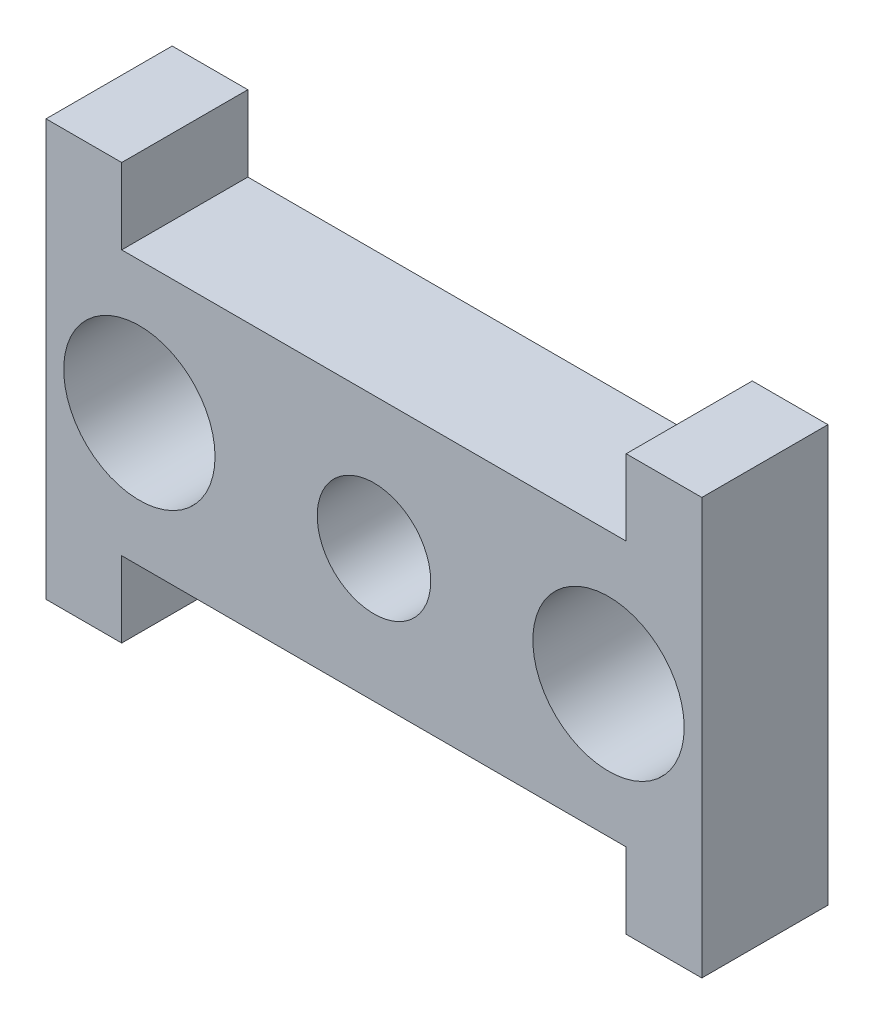
from build123d import *

# Parameters (mm, degrees)
SKETCH1_R           = 3
SKETCH1_R_2         = 2.25
BOSS_EXTRUDE1_DEPTH = 5


with BuildPart() as part:
    # Sketch1 → Boss-Extrude1 (new body)
    with BuildSketch(Plane.XY):
        Polygon((-13, 8.25), (-13, -8.25), (-10, -8.25), (-10, -5.25), (10, -5.25), (10, -8.25), (13, -8.25), (13, 8.25), (10, 8.25), (10, 5.25), (-10, 5.25), (-10, 8.25), align=None)
        with Locations((-9.3, 0)):
            Circle(SKETCH1_R, mode=Mode.SUBTRACT)
        Circle(SKETCH1_R_2, mode=Mode.SUBTRACT)
        with Locations((9.3, 0)):
            Circle(SKETCH1_R, mode=Mode.SUBTRACT)
    extrude(amount=BOSS_EXTRUDE1_DEPTH)


solid = part.part
